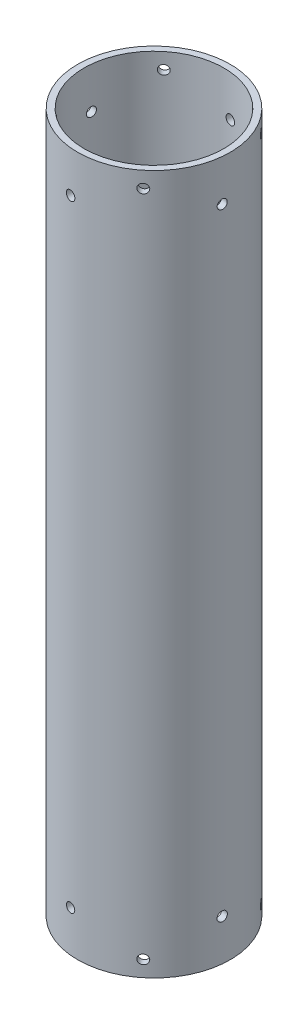
from build123d import *

# Parameters (mm, degrees)
SKETCH_1_R               = 24
SKETCH_1_R_2             = 22
EXTRUDE_1_DEPTH          = 220
SKETCH_2_R               = 1.45
SKETCH_2_R_2             = 1.5
CUT_EXTRUDE_1_DEPTH      = 47.262180774
CUT_EXTRUDE_1_DEPTH_BACK = 7.262180774
SKETCH_3_R               = 1.45
CUT_EXTRUDE_2_DEPTH      = 54.773749072
CUT_EXTRUDE_2_DEPTH_BACK = 14.773749072
SKETCH_5_R               = 1.45
CUT_EXTRUDE_3_DEPTH      = 54.773749072
CUT_EXTRUDE_3_DEPTH_BACK = 14.773749072
SKETCH_4_R               = 1.5
SKETCH_4_R_2             = 1.45
CUT_EXTRUDE_4_DEPTH      = 47.262180884
CUT_EXTRUDE_4_DEPTH_BACK = 7.262180884


with BuildPart() as part:
    # 草图1 → 凸台-拉伸1 (new body)
    with BuildSketch(Plane(origin=(0, 0, 0), x_dir=(1, 0, 0), z_dir=(0, 1, 0))):
        Circle(SKETCH_1_R)
        Circle(SKETCH_1_R_2, mode=Mode.SUBTRACT)
    extrude(amount=EXTRUDE_1_DEPTH)

    # 草图2 → 切除-拉伸1 (cut, two sides)
    with BuildSketch(Plane(origin=(-1.983778232, 0, 19.901372413), x_dir=(-0.995068621, 0, -0.099188912), z_dir=(0.099188912, 0, -0.995068621))) as cut_extrude_1_sk:
        with Locations((0, 13)):
            Circle(SKETCH_2_R)
        with Locations((0, 207)):
            Circle(SKETCH_2_R_2)
    extrude(amount=CUT_EXTRUDE_1_DEPTH, mode=Mode.SUBTRACT)
    extrude(cut_extrude_1_sk.sketch, amount=-CUT_EXTRUDE_1_DEPTH_BACK, mode=Mode.SUBTRACT)

    # 草图3 → 切除-拉伸2 (cut, two sides)
    with BuildSketch(Plane(origin=(12.669652348, 0, 15.475138429), x_dir=(-0.773756921, 0, 0.633482617), z_dir=(-0.633482617, 0, -0.773756921))) as cut_extrude_2_sk:
        with Locations((0, 5)):
            Circle(SKETCH_3_R)
        with Locations((0, 215)):
            Circle(SKETCH_3_R)
    extrude(amount=CUT_EXTRUDE_2_DEPTH, mode=Mode.SUBTRACT)
    extrude(cut_extrude_2_sk.sketch, amount=-CUT_EXTRUDE_2_DEPTH_BACK, mode=Mode.SUBTRACT)

    # 草图5 → 切除-拉伸3 (cut, two sides)
    with BuildSketch(Plane(origin=(15.475138429, 0, -12.669652348), x_dir=(0.633482617, 0, 0.773756921), z_dir=(-0.773756921, 0, 0.633482617))) as cut_extrude_3_sk:
        with Locations((0, 5)):
            Circle(SKETCH_5_R)
        with Locations((0, 215)):
            Circle(SKETCH_5_R)
    extrude(amount=CUT_EXTRUDE_3_DEPTH, mode=Mode.SUBTRACT)
    extrude(cut_extrude_3_sk.sketch, amount=-CUT_EXTRUDE_3_DEPTH_BACK, mode=Mode.SUBTRACT)

    # 草图4 → 切除-拉伸4 (cut, two sides)
    with BuildSketch(Plane(origin=(19.901372413, 0, 1.983778232), x_dir=(-0.099188912, 0, 0.995068621), z_dir=(-0.995068621, 0, -0.099188912))) as cut_extrude_4_sk:
        with Locations((0, 13)):
            Circle(SKETCH_4_R)
        with Locations((0, 207)):
            Circle(SKETCH_4_R_2)
    extrude(amount=CUT_EXTRUDE_4_DEPTH, mode=Mode.SUBTRACT)
    extrude(cut_extrude_4_sk.sketch, amount=-CUT_EXTRUDE_4_DEPTH_BACK, mode=Mode.SUBTRACT)


solid = part.part
